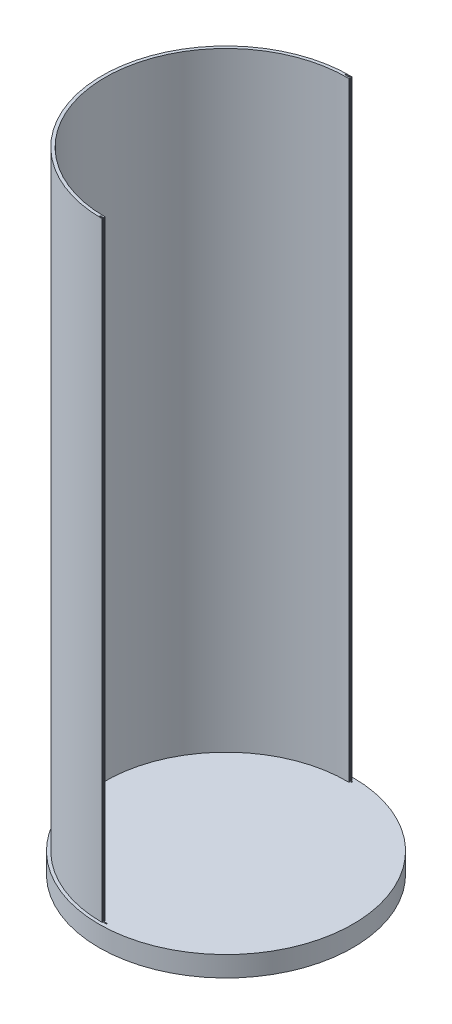
from build123d import *

# Parameters (mm, degrees)
SKETCH1_R           = 62.5
BOSS_EXTRUDE2_DEPTH = 10
EXTRUDE_THIN1_DEPTH = 300
SKETCH8_W           = 3.337239336
SKETCH8_H           = 0.481982953
CUT_EXTRUDE1_DEPTH  = 311


with BuildPart() as part:
    # Sketch1 → Boss-Extrude2 (new body)
    with BuildSketch(Plane(origin=(0, 0, 0), x_dir=(1, 0, 0), z_dir=(0, 1, 0))):
        Circle(SKETCH1_R)
    extrude(amount=BOSS_EXTRUDE2_DEPTH)

    # Sketch4 → Extrude-Thin1 (add)
    with BuildSketch(Plane(origin=(0, 10, 0), x_dir=(1, 0, 0), z_dir=(0, 1, 0))):
        with BuildLine():
            ThreePointArc((0.99996418, 59.491596647), (-59.497899125, 0.499999744), (0, -59.5))
            Line((0, -59.5), (0, -61))
            ThreePointArc((0, -61), (-60.997846161, 0.51260478), (1.025173361, 60.991384798))
            Line((1.025173361, 60.991384798), (0.99996418, 59.491596647))
        make_face()
    extrude(amount=EXTRUDE_THIN1_DEPTH)

    # Sketch8 → Cut-Extrude1 (cut, through all)
    with BuildSketch(Plane(origin=(0, 310, 0), x_dir=(1, 0, 0), z_dir=(0, 1, 0))):
        with Locations((0.042875515, -60.380737202)):
            Rectangle(SKETCH8_W, SKETCH8_H)
    cut_extrude1 = extrude(amount=-CUT_EXTRUDE1_DEPTH, mode=Mode.SUBTRACT)

    # Mirror1: Cut-Extrude1 across plane
    add(cut_extrude1.mirror(Plane.XY), mode=Mode.SUBTRACT)


solid = part.part
